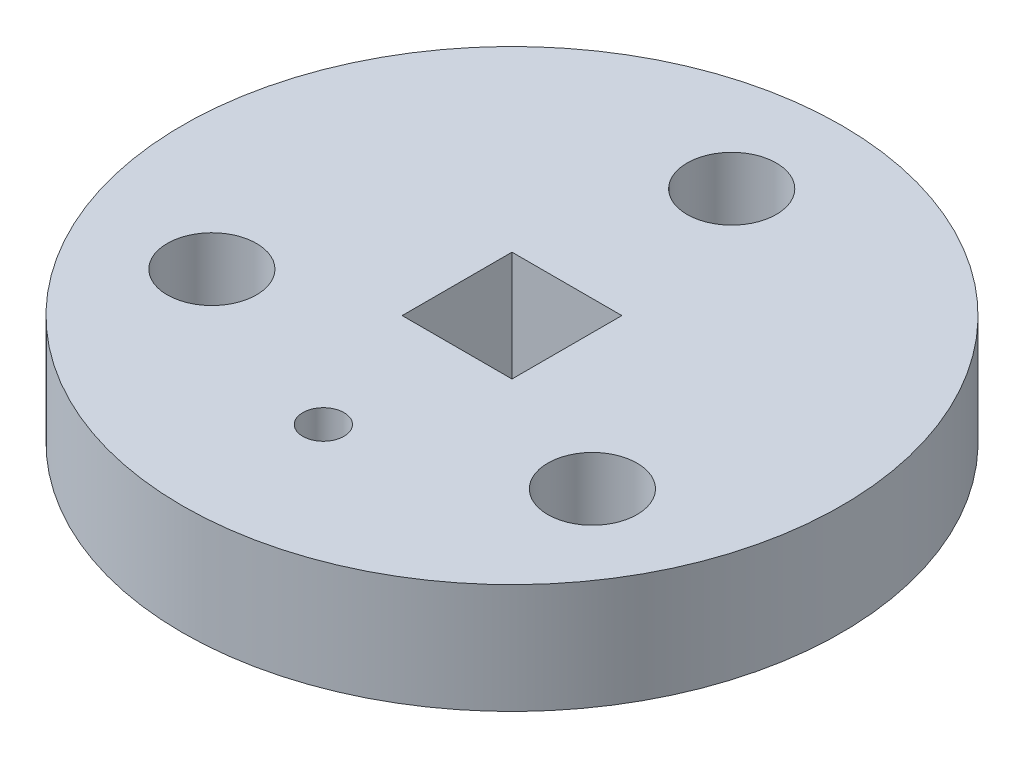
from build123d import *

# Parameters (mm, degrees)
SKETCH1_R           = 19.05
SKETCH1_R_2         = 2.5796875
SKETCH1_W           = 6.35
SKETCH1_H           = 6.35
BOSS_EXTRUDE1_DEPTH = 6.35


with BuildPart() as part:
    # Sketch1 → Boss-Extrude1 (new body)
    with BuildSketch(Plane(origin=(0, 0, 0), x_dir=(1, 0, 0), z_dir=(0, 1, 0))):
        Circle(SKETCH1_R)
        with Locations((0, 12.7)):
            Circle(SKETCH1_R_2, mode=Mode.SUBTRACT)
        with Locations((10.998522628, -6.35)):
            Circle(SKETCH1_R_2, mode=Mode.SUBTRACT)
        with Locations((-10.998522628, -6.35)):
            Circle(SKETCH1_R_2, mode=Mode.SUBTRACT)
        Rectangle(SKETCH1_W, SKETCH1_H, mode=Mode.SUBTRACT)
        with BuildLine():
            ThreePointArc((1.190625, -10.903378281), (0, -9.712753281), (-1.190625, -10.903378281))
            ThreePointArc((-1.190625, -10.903378281), (0, -12.094003281), (1.190625, -10.903378281))
        make_face(mode=Mode.SUBTRACT)
    extrude(amount=BOSS_EXTRUDE1_DEPTH)


solid = part.part
